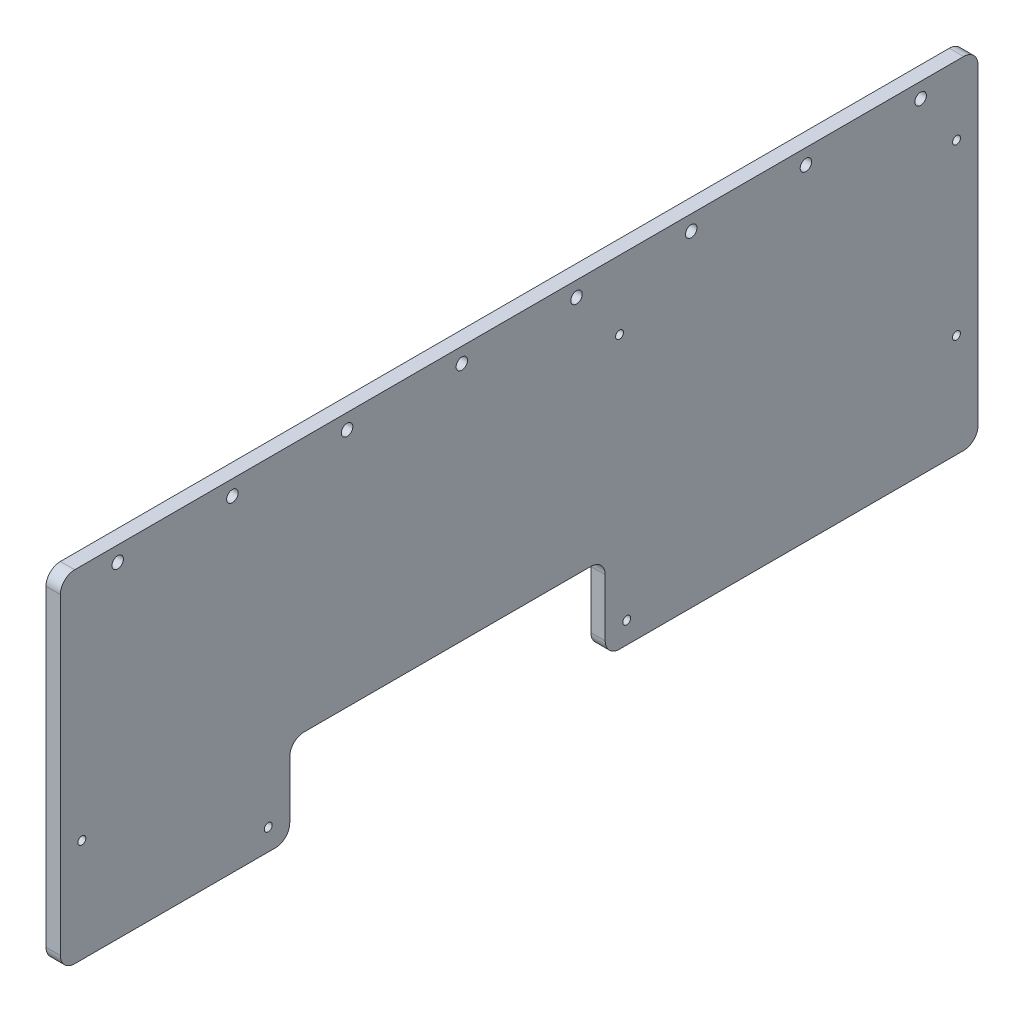
from build123d import *

# Parameters (mm, degrees)
BOSS_EXTRUDE1_DEPTH = 6.35
SKETCH3_R           = 3.96875
CUT_EXTRUDE1_DEPTH  = 7.35
SKETCH5_W           = 6.35
SKETCH5_H           = 12.7
CUT_EXTRUDE3_DEPTH  = 7.35
LPATTERN1_COUNT     = 16
LPATTERN1_PITCH     = 25.4
SKETCH6_W           = 6.35
SKETCH6_H           = 12.7
CUT_EXTRUDE4_DEPTH  = 7.35
LPATTERN2_COUNT     = 11
LPATTERN2_PITCH     = 25.4
SKETCH7_W           = 6.35
SKETCH7_H           = 12.7
SKETCH7_W_2         = 12.7
SKETCH7_H_2         = 6.35
CUT_EXTRUDE5_DEPTH  = 7.35
CUT_EXTRUDE6_DEPTH  = 7.35
LPATTERN3_COUNT     = 10
LPATTERN3_PITCH     = 25.4
SKETCH9_W           = 12.7
SKETCH9_H           = 6.35
CUT_EXTRUDE7_DEPTH  = 7.35
LPATTERN4_COUNT     = 8
LPATTERN4_PITCH     = 25.4
SKETCH10_R          = 3.175
CUT_EXTRUDE8_DEPTH  = 7.35
SKETCH11_R          = 3.96875
CUT_EXTRUDE9_DEPTH  = 7.35
SKETCH12_W          = 6.35
SKETCH12_H          = 12.7
CUT_EXTRUDE13_DEPTH = 7.35
CUT_EXTRUDE15_DEPTH = 7.35
CUT_EXTRUDE16_DEPTH = 7.35
SKETCH17_W          = 12.7
SKETCH17_H          = 6.35
CUT_EXTRUDE17_DEPTH = 7.35
LPATTERN5_COUNT     = 17
LPATTERN5_PITCH     = 25.4
LPATTERN6_COUNT     = 2
LPATTERN6_PITCH     = 120.65
SKETCH18_W          = 12.7
SKETCH18_H          = 6.35
CUT_EXTRUDE18_DEPTH = 7.35
LPATTERN7_COUNT     = 5
LPATTERN7_PITCH     = 25.4
CUT_EXTRUDE19_DEPTH = 7.35
SKETCH20_W          = 101.6
SKETCH20_H          = 57.15
CUT_EXTRUDE20_DEPTH = 7.35
CUT_EXTRUDE21_DEPTH = 7.35
CUT_EXTRUDE22_DEPTH = 7.35
BOSS_EXTRUDE4_DEPTH = 6.35
BOSS_EXTRUDE5_DEPTH = 6.35
SKETCH29_R          = 2.54
CUT_EXTRUDE23_DEPTH = 7.35
SKETCH30_R          = 1.75
CUT_EXTRUDE24_DEPTH = 7.35
SKETCH31_R          = 1.75
CUT_EXTRUDE25_DEPTH = 7.35
FILLET2_R           = 6.35


with BuildPart() as part:
    # Sketch2 → Boss-Extrude1 (new body)
    with BuildSketch(Plane(origin=(0, 0, 0), x_dir=(0, 0, -1), z_dir=(1, 0, 0))):
        Polygon((0, 0), (0, 294.450076882), (215.9, 419.1), (431.8, 419.1), (431.8, 0), (241.3, 0), (241.3, 38.1), (127, 38.1), (127, 0), align=None)
    extrude(amount=BOSS_EXTRUDE1_DEPTH)

    # Sketch3 → Cut-Extrude1 (cut, through all)
    with BuildSketch(Plane(origin=(6.35, 0, 0), x_dir=(0, 0, -1), z_dir=(1, 0, 0))):
        with Locations((63.5, 38.1)):
            Circle(SKETCH3_R)
        with Locations((368.3, 38.1)):
            Circle(SKETCH3_R)
    extrude(amount=-CUT_EXTRUDE1_DEPTH, mode=Mode.SUBTRACT)

    # Sketch5 → Cut-Extrude3 (cut, through all)
    with BuildSketch(Plane(origin=(6.35, 0, 0), x_dir=(0, 0, -1), z_dir=(1, 0, 0))):
        with Locations((428.625, 19.05)):
            Rectangle(SKETCH5_W, SKETCH5_H)
    cut_extrude3 = extrude(amount=-CUT_EXTRUDE3_DEPTH, mode=Mode.SUBTRACT)

    # LPattern1: Cut-Extrude3 ×16
    with Locations(*[(0, i * LPATTERN1_PITCH, 0) for i in range(1, LPATTERN1_COUNT)]):
        add(cut_extrude3, mode=Mode.SUBTRACT)

    # Sketch6 → Cut-Extrude4 (cut, through all)
    with BuildSketch(Plane(origin=(6.35, 0, 0), x_dir=(0, 0, -1), z_dir=(1, 0, 0))):
        with Locations((3.175, 19.05)):
            Rectangle(SKETCH6_W, SKETCH6_H)
    cut_extrude4 = extrude(amount=-CUT_EXTRUDE4_DEPTH, mode=Mode.SUBTRACT)

    # LPattern2: Cut-Extrude4 ×11
    with Locations(*[(0, i * LPATTERN2_PITCH, 0) for i in range(1, LPATTERN2_COUNT)]):
        add(cut_extrude4, mode=Mode.SUBTRACT)

    # Sketch7 → Cut-Extrude5 (cut, through all)
    with BuildSketch(Plane(origin=(6.35, 0, 0), x_dir=(0, 0, -1), z_dir=(1, 0, 0))):
        with Locations((123.825, 19.05)):
            Rectangle(SKETCH7_W, SKETCH7_H)
        with Locations((133.35, 41.275)):
            Rectangle(SKETCH7_W_2, SKETCH7_H_2)
        with Locations((158.75, 41.275)):
            Rectangle(SKETCH7_W_2, SKETCH7_H_2)
        with Locations((184.15, 41.275)):
            Rectangle(SKETCH7_W_2, SKETCH7_H_2)
        with Locations((244.475, 19.05)):
            Rectangle(SKETCH7_W, SKETCH7_H)
        with Locations((209.55, 41.275)):
            Rectangle(SKETCH7_W_2, SKETCH7_H_2)
        with Locations((234.95, 41.275)):
            Rectangle(SKETCH7_W_2, SKETCH7_H_2)
    extrude(amount=-CUT_EXTRUDE5_DEPTH, mode=Mode.SUBTRACT)

    # Sketch8 → Cut-Extrude6 (cut, through all)
    with BuildSketch(Plane(origin=(6.35, 0, 0), x_dir=(0, 0, -1), z_dir=(1, 0, 0))):
        Polygon((201.93507044, 411.037344159), (212.933593068, 417.387344159), (216.108593068, 411.888082845), (205.11007044, 405.538082845), align=None)
    cut_extrude6 = extrude(amount=-CUT_EXTRUDE6_DEPTH, mode=Mode.SUBTRACT)

    # LPattern3: Cut-Extrude6 ×10
    with Locations(*[Vector(0, -0.5, 0.866025404) * (i * LPATTERN3_PITCH) for i in range(1, LPATTERN3_COUNT)]):
        add(cut_extrude6, mode=Mode.SUBTRACT)

    # Sketch9 → Cut-Extrude7 (cut, through all)
    with BuildSketch(Plane(origin=(6.35, 0, 0), x_dir=(0, 0, -1), z_dir=(1, 0, 0))):
        with Locations((412.75, 415.925)):
            Rectangle(SKETCH9_W, SKETCH9_H)
    cut_extrude7 = extrude(amount=-CUT_EXTRUDE7_DEPTH, mode=Mode.SUBTRACT)

    # LPattern4: Cut-Extrude7 ×8
    with Locations(*[(0, 0, i * LPATTERN4_PITCH) for i in range(1, LPATTERN4_COUNT)]):
        add(cut_extrude7, mode=Mode.SUBTRACT)

    # Sketch10 → Cut-Extrude8 (cut, through all)
    with BuildSketch(Plane(origin=(6.35, 0, 0), x_dir=(0, 0, -1), z_dir=(1, 0, 0))):
        with Locations((222.25, 273.05)):
            Circle(SKETCH10_R)
        with Locations((222.25, 57.15)):
            Circle(SKETCH10_R)
        with Locations((146.05, 57.15)):
            Circle(SKETCH10_R)
        with Locations((146.05, 273.05)):
            Circle(SKETCH10_R)
    extrude(amount=-CUT_EXTRUDE8_DEPTH, mode=Mode.SUBTRACT)

    # Sketch11 → Cut-Extrude9 (cut, through all)
    with BuildSketch(Plane(origin=(6.35, 0, 0), x_dir=(0, 0, -1), z_dir=(1, 0, 0))):
        with Locations((38.1, 260.35)):
            Circle(SKETCH11_R)
        with Locations((266.7, 260.35)):
            Circle(SKETCH11_R)
    extrude(amount=-CUT_EXTRUDE9_DEPTH, mode=Mode.SUBTRACT)

    # Sketch12 → Cut-Extrude13 (cut, through all)
    with BuildSketch(Plane(origin=(6.35, 0, 0), x_dir=(0, 0, -1), z_dir=(1, 0, 0))):
        with Locations((123.825, 44.45)):
            Rectangle(SKETCH12_W, SKETCH12_H)
        with Locations((123.825, 69.85)):
            Rectangle(SKETCH12_W, SKETCH12_H)
        with Locations((123.825, 95.25)):
            Rectangle(SKETCH12_W, SKETCH12_H)
        with Locations((123.825, 120.65)):
            Rectangle(SKETCH12_W, SKETCH12_H)
    cut_extrude13 = extrude(amount=-CUT_EXTRUDE13_DEPTH, mode=Mode.SUBTRACT)

    # Sketch14 → Cut-Extrude15 (cut, through all)
    with BuildSketch(Plane(origin=(6.35, 0, 0), x_dir=(0, 0, -1), z_dir=(1, 0, 0))):
        Polygon((36.957231019, 315.787344159), (47.955753647, 322.137344159), (51.130753647, 316.638082845), (40.132231019, 310.288082845), align=None)
        Polygon((80.951321531, 341.187344159), (91.949844159, 347.537344159), (95.124844159, 342.038082845), (84.126321531, 335.688082845), align=None)
    extrude(amount=-CUT_EXTRUDE15_DEPTH, mode=Mode.SUBTRACT)

    # Sketch15 → Cut-Extrude16 (cut, through all)
    with BuildSketch(Plane(origin=(6.35, 0, 0), x_dir=(0, 0, -1), z_dir=(1, 0, 0))):
        with BuildLine():
            Line((62.129276275, 322.988082845), (31.558579521, 305.338082845))
            ThreePointArc((31.558579521, 305.338082845), (51.535904978, 302.314952438), (62.501260575, 319.285333297))
            ThreePointArc((62.501260575, 319.285333297), (62.408031035, 321.146027155), (62.129276275, 322.988082845))
        make_face()
        with BuildLine():
            Line((103.698495657, 346.988082845), (73.127798903, 329.338082845))
            ThreePointArc((73.127798903, 329.338082845), (93.10512436, 326.314952438), (104.070479957, 343.285333297))
            ThreePointArc((104.070479957, 343.285333297), (103.977250417, 345.146027155), (103.698495657, 346.988082845))
        make_face()
    extrude(amount=-CUT_EXTRUDE16_DEPTH, mode=Mode.SUBTRACT)

    # Sketch17 → Cut-Extrude17 (cut, through all)
    with BuildSketch(Plane(origin=(6.35, 0, 0), x_dir=(0, 0, -1), z_dir=(1, 0, 0))):
        with Locations((25.4, 142.875)):
            Rectangle(SKETCH17_W, SKETCH17_H)
    cut_extrude17 = extrude(amount=-CUT_EXTRUDE17_DEPTH, mode=Mode.SUBTRACT)

    # LPattern5: Cut-Extrude17 ×17
    with Locations(*[(0, 0, -i * LPATTERN5_PITCH) for i in range(1, LPATTERN5_COUNT)]):
        add(cut_extrude17, mode=Mode.SUBTRACT)

    # LPattern6: Cut-Extrude13 ×2
    with Locations(*[(0, 0, -i * LPATTERN6_PITCH) for i in range(1, LPATTERN6_COUNT)]):
        add(cut_extrude13, mode=Mode.SUBTRACT)

    # Sketch18 → Cut-Extrude18 (cut, through all)
    with BuildSketch(Plane(origin=(6.35, 0, 0), x_dir=(0, 0, -1), z_dir=(1, 0, 0))):
        with Locations((133.35, 117.475)):
            Rectangle(SKETCH18_W, SKETCH18_H)
    cut_extrude18 = extrude(amount=-CUT_EXTRUDE18_DEPTH, mode=Mode.SUBTRACT)

    # LPattern7: Cut-Extrude18 ×5
    with Locations(*[(0, 0, -i * LPATTERN7_PITCH) for i in range(1, LPATTERN7_COUNT)]):
        add(cut_extrude18, mode=Mode.SUBTRACT)

    # Sketch19 → Cut-Extrude19 (cut, through all)
    with BuildSketch(Plane(origin=(6.35, 0, 0), x_dir=(0, 0, -1), z_dir=(1, 0, 0))):
        Polygon((25.4, 279.785380045), (222.705909488, 393.7), (406.4, 393.7), (406.4, 165.1), (25.4, 165.1), align=None)
    extrude(amount=-CUT_EXTRUDE19_DEPTH, mode=Mode.SUBTRACT)

    # Sketch20 → Cut-Extrude20 (cut, through all)
    with BuildSketch(Plane(origin=(6.35, 0, 0), x_dir=(0, 0, -1), z_dir=(1, 0, 0))):
        with Locations((184.15, 79.375)):
            Rectangle(SKETCH20_W, SKETCH20_H)
    extrude(amount=-CUT_EXTRUDE20_DEPTH, mode=Mode.SUBTRACT)

    # Sketch21 → Cut-Extrude21 (cut, through all)
    with BuildSketch(Plane(origin=(6.35, 0, 0), x_dir=(0, 0, -1), z_dir=(1, 0, 0))):
        Polygon((266.7, 25.4), (308.202954744, 25.4), (406.4, 82.094090512), (406.4, 133.35), (266.7, 133.35), align=None)
        Polygon((25.4, 133.35), (25.4, 82.094090512), (101.6, 38.1), (101.6, 133.35), align=None)
        Polygon((25.4, 38.1), (25.4, 25.4), (47.397045256, 25.4), align=None)
    extrude(amount=-CUT_EXTRUDE21_DEPTH, mode=Mode.SUBTRACT)

    # Sketch22 → Cut-Extrude22 (cut, through all)
    with BuildSketch(Plane(origin=(6.35, 0, 0), x_dir=(0, 0, -1), z_dir=(1, 0, 0))):
        Polygon((384.402954744, 25.4), (406.4, 38.1), (406.4, 25.4), align=None)
    extrude(amount=-CUT_EXTRUDE22_DEPTH, mode=Mode.SUBTRACT)

    # Sketch26 → Boss-Extrude4 (add, through all)
    with BuildSketch(Plane(origin=(6.35, 0, 0), x_dir=(0, 0, -1), z_dir=(1, 0, 0))):
        Polygon((266.7, 133.35), (266.7, 126.280871047), (278.944090512, 133.35), align=None)
        Polygon((89.355909488, 133.35), (101.6, 126.280871047), (101.6, 133.35), align=None)
        Polygon((266.7, 32.469128953), (278.944090512, 25.4), (266.7, 25.4), align=None)
        Polygon((133.35, 107.95), (133.35, 100.880871047), (145.594090512, 107.95), align=None)
        Polygon((234.95, 107.95), (222.705909488, 107.95), (234.95, 100.880871047), align=None)
        Polygon((133.35, 50.8), (145.594090512, 50.8), (133.35, 57.869128953), align=None)
        Polygon((234.95, 50.8), (222.705909488, 50.8), (234.95, 57.869128953), align=None)
    extrude(amount=-BOSS_EXTRUDE4_DEPTH)


with BuildPart() as body_2:
    # Sketch27 → Boss-Extrude5 (new body)
    with BuildSketch(Plane(origin=(6.35, 0, 0), x_dir=(0, 0, -1), z_dir=(1, 0, 0))):
        Polygon((12.7, 163.83), (12.7, 12.7), (114.3, 12.7), (114.3, 50.8), (254, 50.8), (254, 12.7), (419.1, 12.7), (419.1, 163.83), align=None)
    extrude(amount=-BOSS_EXTRUDE5_DEPTH)

    # Sketch29 → Cut-Extrude23 (cut, through all)
    with BuildSketch(Plane(origin=(6.35, 0, 0), x_dir=(0, 0, -1), z_dir=(1, 0, 0))):
        with Locations((38.1, 157.1625)):
            Circle(SKETCH29_R)
        with Locations((88.9, 157.1625)):
            Circle(SKETCH29_R)
        with Locations((139.7, 157.1625)):
            Circle(SKETCH29_R)
        with Locations((190.5, 157.1625)):
            Circle(SKETCH29_R)
        with Locations((241.3, 157.1625)):
            Circle(SKETCH29_R)
        with Locations((292.1, 157.1625)):
            Circle(SKETCH29_R)
        with Locations((342.9, 157.1625)):
            Circle(SKETCH29_R)
        with Locations((393.7, 157.1625)):
            Circle(SKETCH29_R)
    extrude(amount=-CUT_EXTRUDE23_DEPTH, mode=Mode.SUBTRACT)

    # Sketch30 → Cut-Extrude24 (cut, through all)
    with BuildSketch(Plane(origin=(6.35, 0, 0), x_dir=(0, 0, -1), z_dir=(1, 0, 0))):
        with Locations((22.225, 58.42)):
            Circle(SKETCH30_R)
        with Locations((104.775, 22.225)):
            Circle(SKETCH30_R)
        with Locations((263.525, 22.225)):
            Circle(SKETCH30_R)
        with Locations((409.575, 58.42)):
            Circle(SKETCH30_R)
    extrude(amount=-CUT_EXTRUDE24_DEPTH, mode=Mode.SUBTRACT)

    # Sketch31 → Cut-Extrude25 (cut, through all)
    with BuildSketch(Plane(origin=(6.35, 0, 0), x_dir=(0, 0, -1), z_dir=(1, 0, 0))):
        with Locations((260.35, 133.35)):
            Circle(SKETCH31_R)
        with Locations((409.575, 133.35)):
            Circle(SKETCH31_R)
    extrude(amount=-CUT_EXTRUDE25_DEPTH, mode=Mode.SUBTRACT)

    # Fillet2
    fillet2_edges = [body_2.edges().sort_by_distance(p)[0] for p in [
        (3.175, 163.83, -419.1),
        (3.175, 12.7, -419.1),
        (3.175, 12.7, -254),
        (3.175, 50.8, -254),
        (3.175, 50.8, -114.3),
        (3.175, 12.7, -114.3),
        (3.175, 12.7, -12.7),
        (3.175, 163.83, -12.7),
    ]]
    fillet(fillet2_edges, radius=FILLET2_R)


solid = body_2.part
